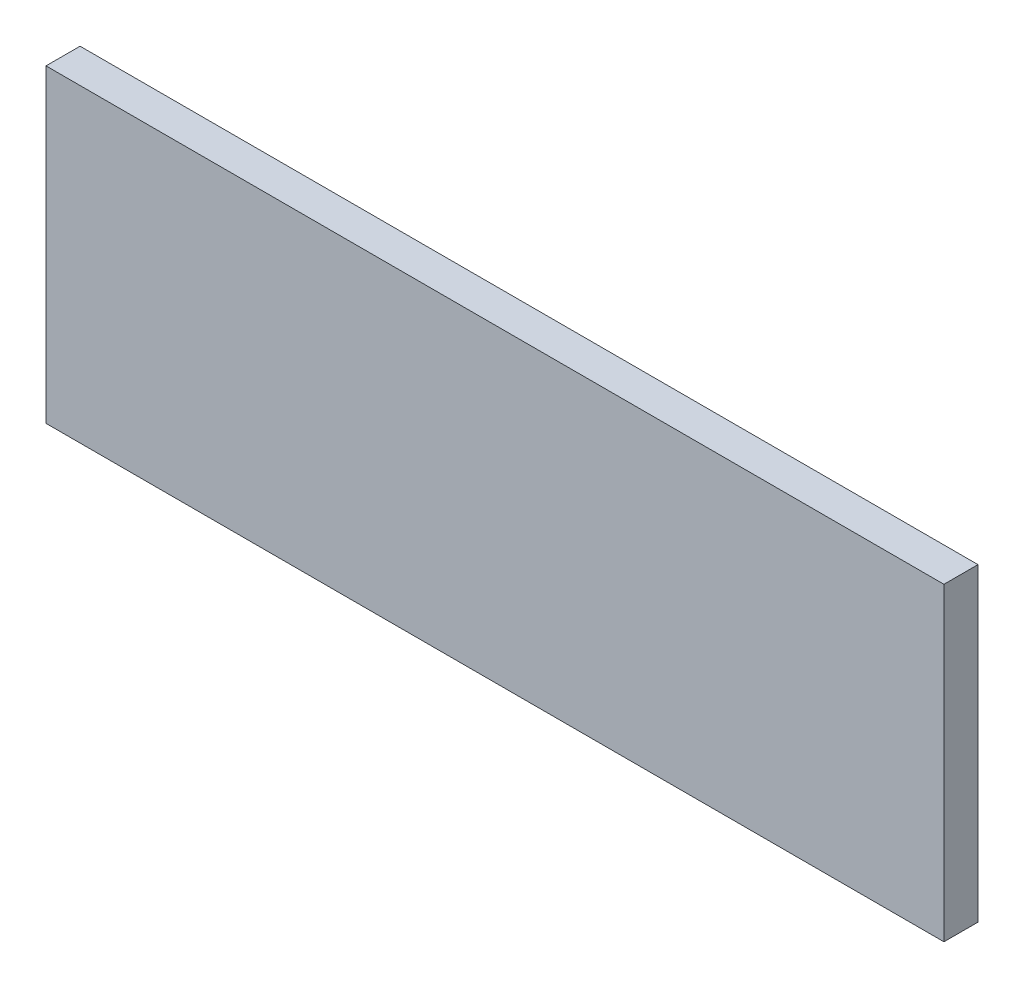
from build123d import *

# Parameters (mm, degrees)
SKETCH1_W           = 580
SKETCH1_H           = 200
BOSS_EXTRUDE1_DEPTH = 22


with BuildPart() as part:
    # Sketch1 → Boss-Extrude1 (new body)
    with BuildSketch(Plane.XY):
        Rectangle(SKETCH1_W, SKETCH1_H)
    extrude(amount=BOSS_EXTRUDE1_DEPTH)


solid = part.part
